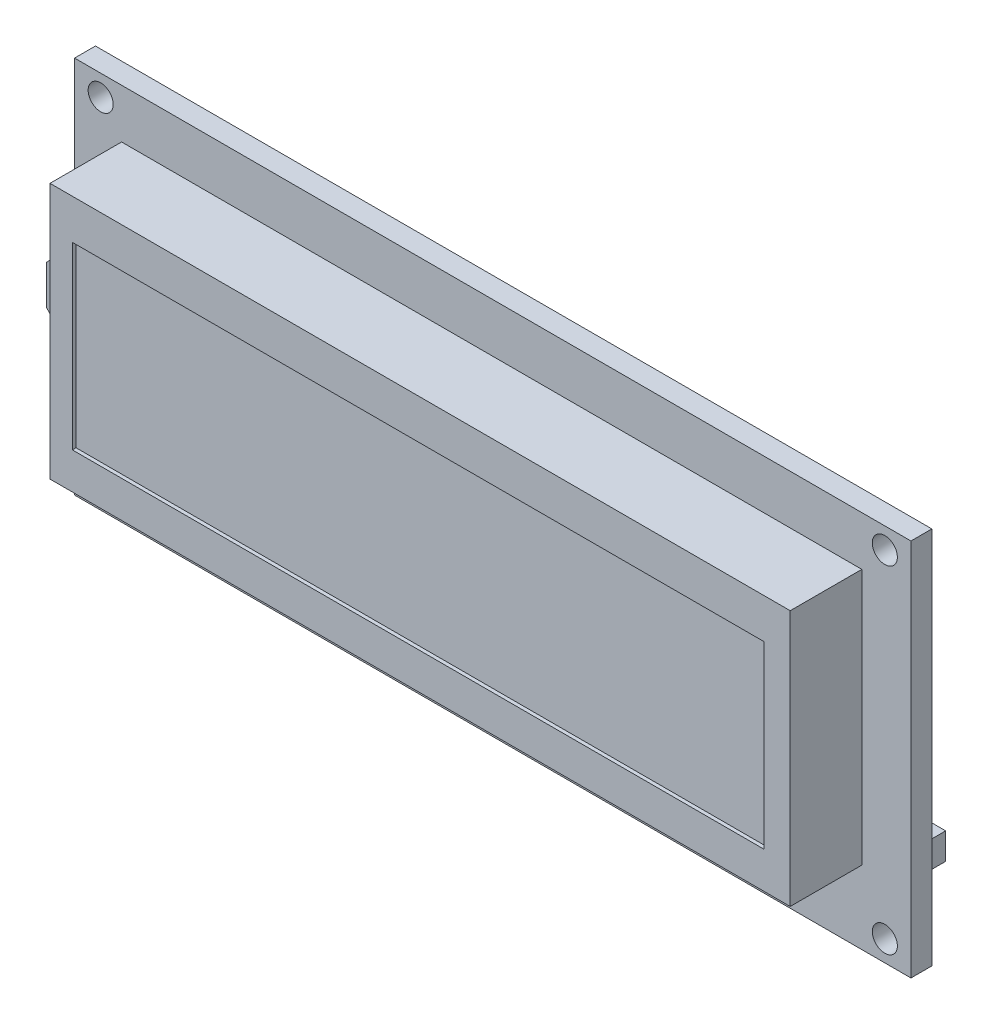
from build123d import *

# Parameters (mm, degrees)
SKETCH_2_W      = 80
SKETCH_2_H      = 36.2
SKETCH_2_R      = 1.2
EXTRUDE_1_DEPTH = 2
SKETCH_3_W      = 70.8
SKETCH_3_H      = 24.5
SKETCH_3_W_2    = 66.149074023
SKETCH_3_H_2    = 17.195468247
EXTRUDE_2_DEPTH = 8.849661681
SKETCH_4_W      = 66.149074023
SKETCH_4_H      = 17.195468247
EXTRUDE_3_DEPTH = 6.5
SKETCH_6_W      = 41
SKETCH_6_H      = 2.53
SKETCH_6_W_2    = 1
SKETCH_6_H_2    = 1
EXTRUDE_4_DEPTH = 10.32
EXTRUDE_5_DEPTH = 2.7
SKETCH_8_W      = 7.322472125
SKETCH_8_H      = 3.20872374
EXTRUDE_6_DEPTH = 2.5


with BuildPart() as part:
    # 草图2 → 凸台-拉伸1 (new body)
    with BuildSketch(Plane.XY):
        with Locations((-34.091991963, -13.838432836)):
            Rectangle(SKETCH_2_W, SKETCH_2_H)
        with Locations((3.408008037, -29.938432836)):
            Circle(SKETCH_2_R, mode=Mode.SUBTRACT)
        with Locations((-71.591991963, 2.261567164)):
            Circle(SKETCH_2_R, mode=Mode.SUBTRACT)
        with Locations((3.408008037, 2.261567164)):
            Circle(SKETCH_2_R, mode=Mode.SUBTRACT)
        with Locations((-71.591991963, -29.938432836)):
            Circle(SKETCH_2_R, mode=Mode.SUBTRACT)
    extrude(amount=EXTRUDE_1_DEPTH)

    # 草图3 → 凸台-拉伸2 (add)
    with BuildSketch(Plane.XY):
        with Locations((-34.191991963, -12.688432836)):
            Rectangle(SKETCH_3_W, SKETCH_3_H)
        with Locations((-34.379954351, -12.851133223)):
            Rectangle(SKETCH_3_W_2, SKETCH_3_H_2, mode=Mode.SUBTRACT)
    extrude(amount=EXTRUDE_2_DEPTH)

    # 草图6 → 凸台-拉伸4 (add)
    with BuildSketch(Plane.XY.offset(2)):
        with Locations((-21.591991963, -29.673432836)):
            Rectangle(SKETCH_6_W, SKETCH_6_H)
        with Locations((-5.190328845, -29.731482843)):
            Rectangle(SKETCH_6_W_2, SKETCH_6_H_2, mode=Mode.SUBTRACT)
        with Locations((-2.670328845, -29.731482843)):
            Rectangle(SKETCH_6_W_2, SKETCH_6_H_2, mode=Mode.SUBTRACT)
        with Locations((-7.710328845, -29.731482843)):
            Rectangle(SKETCH_6_W_2, SKETCH_6_H_2, mode=Mode.SUBTRACT)
        with Locations((-10.230328845, -29.731482843)):
            Rectangle(SKETCH_6_W_2, SKETCH_6_H_2, mode=Mode.SUBTRACT)
        with Locations((-12.750328845, -29.731482843)):
            Rectangle(SKETCH_6_W_2, SKETCH_6_H_2, mode=Mode.SUBTRACT)
        with Locations((-15.270328845, -29.731482843)):
            Rectangle(SKETCH_6_W_2, SKETCH_6_H_2, mode=Mode.SUBTRACT)
        with Locations((-17.790328845, -29.731482843)):
            Rectangle(SKETCH_6_W_2, SKETCH_6_H_2, mode=Mode.SUBTRACT)
        with Locations((-20.310328845, -29.731482843)):
            Rectangle(SKETCH_6_W_2, SKETCH_6_H_2, mode=Mode.SUBTRACT)
        with Locations((-22.830328845, -29.731482843)):
            Rectangle(SKETCH_6_W_2, SKETCH_6_H_2, mode=Mode.SUBTRACT)
        with Locations((-25.350328845, -29.731482843)):
            Rectangle(SKETCH_6_W_2, SKETCH_6_H_2, mode=Mode.SUBTRACT)
        with Locations((-27.870328845, -29.731482843)):
            Rectangle(SKETCH_6_W_2, SKETCH_6_H_2, mode=Mode.SUBTRACT)
        with Locations((-30.390328845, -29.731482843)):
            Rectangle(SKETCH_6_W_2, SKETCH_6_H_2, mode=Mode.SUBTRACT)
        with Locations((-32.910328845, -29.731482843)):
            Rectangle(SKETCH_6_W_2, SKETCH_6_H_2, mode=Mode.SUBTRACT)
        with Locations((-35.430328845, -29.731482843)):
            Rectangle(SKETCH_6_W_2, SKETCH_6_H_2, mode=Mode.SUBTRACT)
        with Locations((-37.950328845, -29.731482843)):
            Rectangle(SKETCH_6_W_2, SKETCH_6_H_2, mode=Mode.SUBTRACT)
        with Locations((-40.470328845, -29.731482843)):
            Rectangle(SKETCH_6_W_2, SKETCH_6_H_2, mode=Mode.SUBTRACT)
    extrude(amount=-EXTRUDE_4_DEPTH)

    # 草图7 → 凸台-拉伸5 (add)
    with BuildSketch(Plane.XY.offset(2)):
        Polygon((-69.591991963, -19.438432836), (-69.591991963, -6.438432836), (-74.091991963, -11.324147122), (-74.091991963, -15.045770955), align=None)
    extrude(amount=EXTRUDE_5_DEPTH)

    # 草图8 → 凸台-拉伸6 (add)
    with BuildSketch(Plane(origin=(0, 0, 0), x_dir=(-1, 0, 0), z_dir=(0, 0, -1))):
        with Locations((33.871678046, -3.71861181)):
            Rectangle(SKETCH_8_W, SKETCH_8_H)
        with Locations((5.871678045, -3.71861181)):
            Rectangle(SKETCH_8_W, SKETCH_8_H)
        with Locations((61.871678046, -3.71861181)):
            Rectangle(SKETCH_8_W, SKETCH_8_H)
        with Locations((33.871678046, -23.71861181)):
            Rectangle(SKETCH_8_W, SKETCH_8_H)
        with Locations((61.871678046, -23.71861181)):
            Rectangle(SKETCH_8_W, SKETCH_8_H)
        with Locations((5.871678045, -23.71861181)):
            Rectangle(SKETCH_8_W, SKETCH_8_H)
    extrude(amount=EXTRUDE_6_DEPTH)


with BuildPart() as body_2:
    # 草图4 → 凸台-拉伸3 (new body)
    with BuildSketch(Plane.XY.offset(2)):
        with Locations((-34.379954351, -12.851133223)):
            Rectangle(SKETCH_4_W, SKETCH_4_H)
    extrude(amount=EXTRUDE_3_DEPTH)


solid = Compound([part.part, body_2.part])
